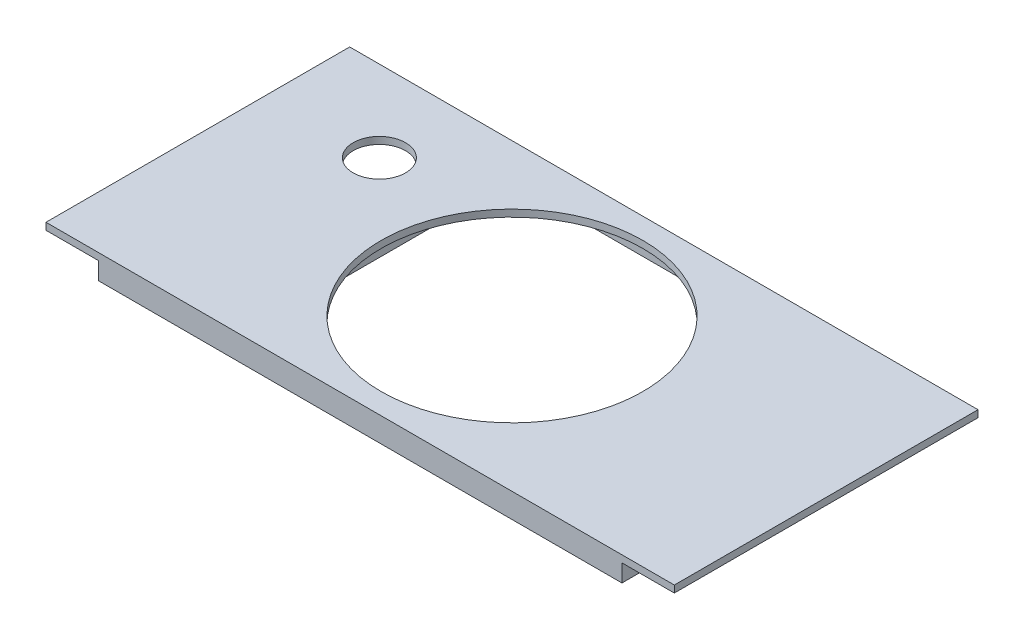
from build123d import *

# Parameters (mm, degrees)
SKETCH1_W           = 180
SKETCH1_H           = 87
BOSS_EXTRUDE1_DEPTH = 2
SKETCH6_W           = 2
SKETCH6_H           = 87
BOSS_EXTRUDE5_DEPTH = 5
SKETCH7_R           = 37.5
CUT_EXTRUDE2_DEPTH  = 5
SKETCH8_W           = 87
SKETCH8_H           = 87
SKETCH8_W_2         = 81
SKETCH8_H_2         = 81
BOSS_EXTRUDE6_DEPTH = 5
SKETCH9_W           = 150
SKETCH9_H           = 3
BOSS_EXTRUDE7_DEPTH = 5
SKETCH10_W          = 2
SKETCH10_H          = 87
CUT_EXTRUDE3_DEPTH  = 5
SKETCH11_W          = 2
SKETCH11_H          = 81
BOSS_EXTRUDE8_DEPTH = 5
SKETCH12_R          = 7.5
CUT_EXTRUDE4_DEPTH  = 5


with BuildPart() as part:
    # Sketch1 → Boss-Extrude1 (new body)
    with BuildSketch(Plane(origin=(0, 0, 0), x_dir=(1, 0, 0), z_dir=(0, 1, 0))):
        with Locations((31.597011279, 2.798063398)):
            Rectangle(SKETCH1_W, SKETCH1_H)
    extrude(amount=BOSS_EXTRUDE1_DEPTH)

    # Sketch6 → Boss-Extrude5 (add)
    with BuildSketch(Plane(origin=(0, 0, 0), x_dir=(-1, 0, 0), z_dir=(0, -1, 0))):
        with Locations((44.402988721, 2.798063398)):
            Rectangle(SKETCH6_W, SKETCH6_H)
        with Locations((-107.597011279, 2.798063398)):
            Rectangle(SKETCH6_W, SKETCH6_H)
    extrude(amount=BOSS_EXTRUDE5_DEPTH)

    # Sketch7 → Cut-Extrude2 (cut)
    with BuildSketch(Plane(origin=(0, 0, 0), x_dir=(-1, 0, 0), z_dir=(0, -1, 0))):
        with Locations((-31.597011279, 2.798063398)):
            Circle(SKETCH7_R)
    extrude(amount=-CUT_EXTRUDE2_DEPTH, mode=Mode.SUBTRACT)

    # Sketch8 → Boss-Extrude6 (add)
    with BuildSketch(Plane(origin=(0, 0, 0), x_dir=(-1, 0, 0), z_dir=(0, -1, 0))):
        with Locations((-31.597011279, 2.798063398)):
            Rectangle(SKETCH8_W, SKETCH8_H)
        with Locations((-31.597011279, 2.798063398)):
            Rectangle(SKETCH8_W_2, SKETCH8_H_2, mode=Mode.SUBTRACT)
    extrude(amount=BOSS_EXTRUDE6_DEPTH)

    # Sketch9 → Boss-Extrude7 (add)
    with BuildSketch(Plane(origin=(0, 0, 0), x_dir=(-1, 0, 0), z_dir=(0, -1, 0))):
        with Locations((-31.597011279, 44.798063398)):
            Rectangle(SKETCH9_W, SKETCH9_H)
        with Locations((-31.597011279, -39.201936602)):
            Rectangle(SKETCH9_W, SKETCH9_H)
    extrude(amount=BOSS_EXTRUDE7_DEPTH)

    # Sketch10 → Cut-Extrude3 (cut)
    with BuildSketch(Plane(origin=(0, -5, 0), x_dir=(-1, 0, 0), z_dir=(0, -1, 0))):
        with Locations((-107.597011279, 2.798063398)):
            Rectangle(SKETCH10_W, SKETCH10_H)
        with Locations((44.402988721, 2.798063398)):
            Rectangle(SKETCH10_W, SKETCH10_H)
    extrude(amount=-CUT_EXTRUDE3_DEPTH, mode=Mode.SUBTRACT)

    # Sketch11 → Boss-Extrude8 (add)
    with BuildSketch(Plane(origin=(0, 0, 0), x_dir=(-1, 0, 0), z_dir=(0, -1, 0))):
        with Locations((42.402988721, 2.798063398)):
            Rectangle(SKETCH11_W, SKETCH11_H)
        with Locations((-105.597011279, 2.798063398)):
            Rectangle(SKETCH11_W, SKETCH11_H)
    extrude(amount=BOSS_EXTRUDE8_DEPTH)

    # Sketch12 → Cut-Extrude4 (cut)
    with BuildSketch(Plane(origin=(0, 0, 0), x_dir=(-1, 0, 0), z_dir=(0, -1, 0))):
        with Locations((26.652988721, 23.048063398)):
            Circle(SKETCH12_R)
    extrude(amount=-CUT_EXTRUDE4_DEPTH, mode=Mode.SUBTRACT)


solid = part.part
